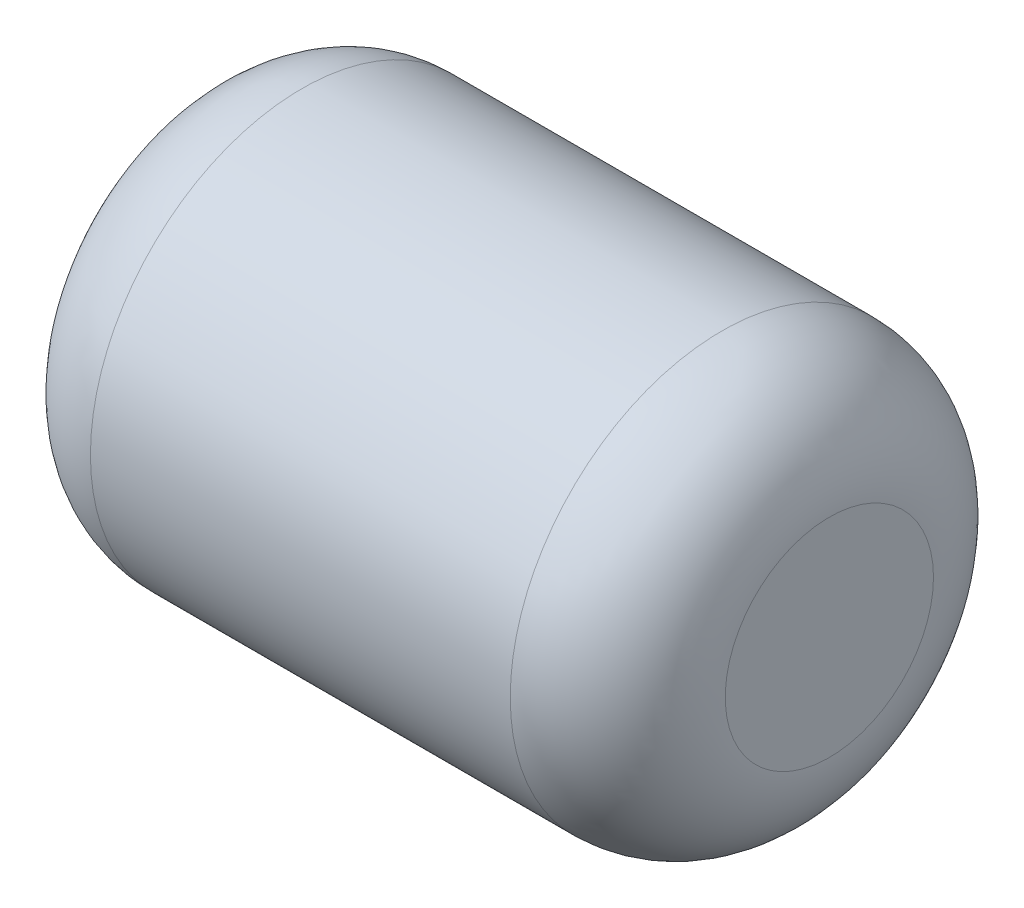
from build123d import *

# Parameters (mm, degrees)
SKETCH1_R      = 1
EXTRUDE1_DEPTH = 3
FILLET1_R      = 0.508


with BuildPart() as part:
    # Sketch1 → Extrude1 (new body)
    with BuildSketch(Plane(origin=(0, 0, 0), x_dir=(0, 0, -1), z_dir=(1, 0, 0))):
        Circle(SKETCH1_R)
    extrude(amount=EXTRUDE1_DEPTH)

    # Fillet1
    fillet1_edges = [part.edges().sort_by_distance(p)[0] for p in [
        (0, 0, 1),
        (3, 0, 1),
    ]]
    fillet(fillet1_edges, radius=FILLET1_R)


solid = part.part
